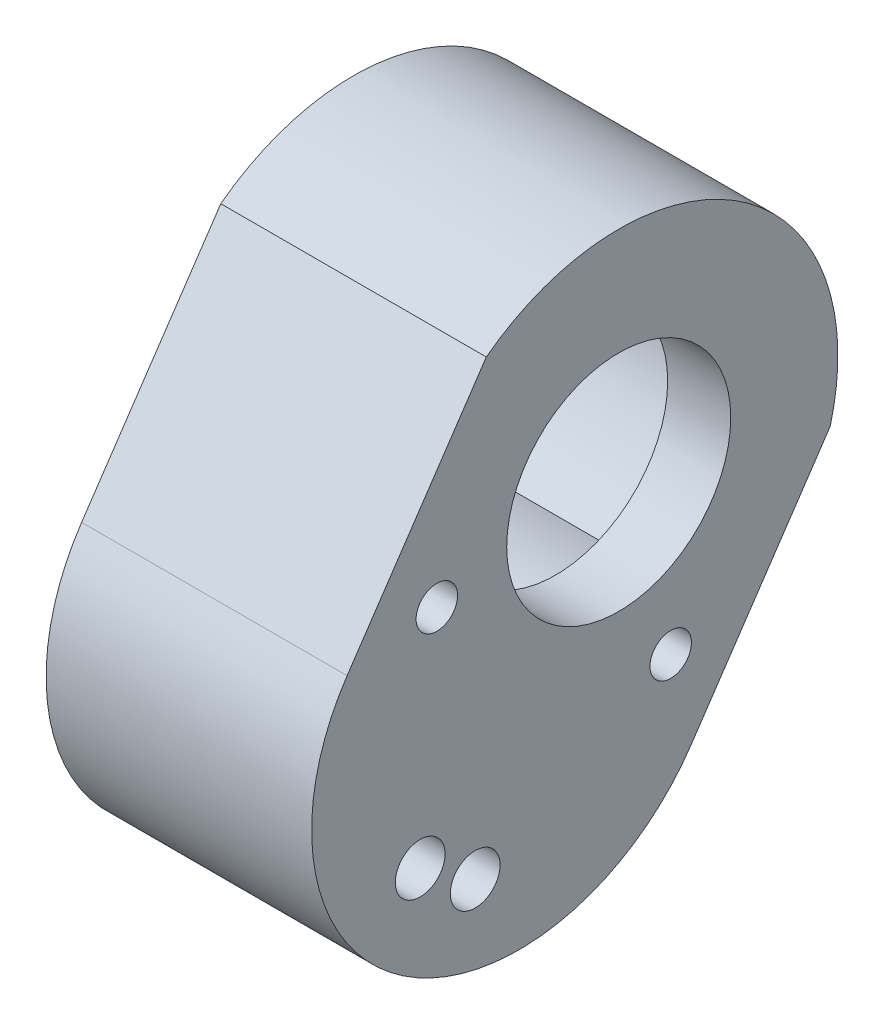
from build123d import *

# Parameters (mm, degrees)
EXTRUDE_START            = 1.3
EXTRUDE_1_DEPTH          = 16
CUT_EXTRUDE_1_DEPTH      = 13.5
SKETCH_1_4_R             = 6.75
CUT_EXTRUDE_2_DEPTH      = 75.808647209
EXTRUDE_START_2          = 10
EXTRUDE_2_DEPTH          = 10
CUT_EXTRUDE_4_DEPTH      = 74.796230915
CUT_EXTRUDE_4_DEPTH_BACK = 74.796230915
SKETCH_3_R               = 1.25
SKETCH_3_R_2             = 1.5


with BuildPart() as part:
    # 草图1 → 凸台-拉伸1 (new body)
    with BuildSketch(Plane(origin=(0, 0, 0), x_dir=(0, 0, -1), z_dir=(1, 0, 0)).offset(EXTRUDE_START)):
        with BuildLine():
            Line((23.574545879, 54.705015226), (15.186652327, 42.269451638))
            ThreePointArc((15.186652327, 42.269451638), (18.559710691, 24.916570688), (35.912591641, 28.289629051))
            Line((35.912591641, 28.289629051), (44.300485193, 40.72519264))
            ThreePointArc((44.300485193, 40.72519264), (38.939692203, 55.131135816), (23.574545879, 54.705015226))
        make_face()
    extrude(amount=EXTRUDE_1_DEPTH)

    # 草图1<3> → 切除-拉伸1 (cut)
    with BuildSketch(Plane(origin=(0, 0, 0), x_dir=(0, 0, -1), z_dir=(1, 0, 0))):
        with BuildLine():
            ThreePointArc((20.461625434, 46.334508412), (37.873723753, 53.550772599), (37.705606944, 34.70329602))
            ThreePointArc((37.705606944, 34.70329602), (20.293508625, 27.487031833), (20.461625434, 46.334508412))
        make_face()
    extrude(amount=CUT_EXTRUDE_1_DEPTH, mode=Mode.SUBTRACT)

    # 草图1<4> → 切除-拉伸2 (cut, through all)
    with BuildSketch(Plane(origin=(0, 0, 0), x_dir=(0, 0, -1), z_dir=(1, 0, 0))):
        with Locations((31.554843944, 44.182648029)):
            Circle(SKETCH_1_4_R)
    extrude(amount=CUT_EXTRUDE_2_DEPTH, mode=Mode.SUBTRACT)

    # 草图2 → 凸台-拉伸2 (add)
    with BuildSketch(Plane.ZY.offset(-13.5).offset(EXTRUDE_START_2)):
        with BuildLine():
            ThreePointArc((-20.461625434, 46.334508412), (-37.873723753, 53.550772599), (-37.705606944, 34.70329602))
            ThreePointArc((-37.705606944, 34.70329602), (-20.293508625, 27.487031833), (-20.461625434, 46.334508412))
        make_face()
        with BuildLine():
            ThreePointArc((-36.796785017, 35.31630415), (-20.852701529, 28.316069405), (-21.370447361, 45.721500282))
            ThreePointArc((-21.370447361, 45.721500282), (-37.314530849, 52.721735026), (-36.796785017, 35.31630415))
        make_face(mode=Mode.SUBTRACT)
    extrude(amount=-EXTRUDE_2_DEPTH)

    # 草图3 → 切除-拉伸4 (cut, two sides: drawn at the far end of the back side and taken through both)
    with BuildSketch(Plane.ZY.offset(-13.5).offset(-CUT_EXTRUDE_4_DEPTH_BACK)):
        with Locations((-34.687312986, 33.626245342)):
            Circle(SKETCH_3_R)
        with Locations((-20.593674253, 43.132524701)):
            Circle(SKETCH_3_R)
        with Locations((-22.9057078, 27.783193072)):
            Circle(SKETCH_3_R_2)
        with Locations((-19.58955751, 30.019964685)):
            Circle(SKETCH_3_R_2)
    extrude(amount=CUT_EXTRUDE_4_DEPTH + CUT_EXTRUDE_4_DEPTH_BACK, mode=Mode.SUBTRACT)


solid = part.part
